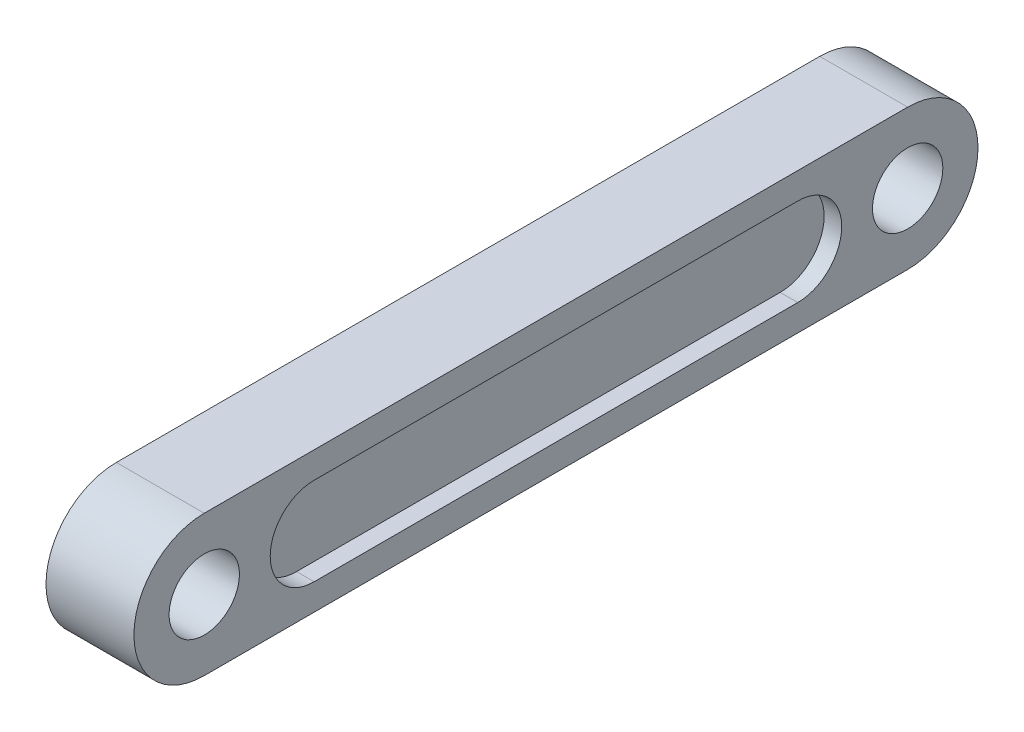
from build123d import *

# Parameters (mm, degrees)
SKETCH_1_R          = 4
EXTRUDE_1_DEPTH     = 5
CUT_EXTRUDE_1_DEPTH = 2


with BuildPart() as part:
    # 草图1 → 凸台-拉伸1 (new body, symmetric)
    with BuildSketch(Plane(origin=(0, 0, 0), x_dir=(0, 0, -1), z_dir=(1, 0, 0))):
        with BuildLine():
            Line((-40, 8), (40, 8))
            ThreePointArc((40, 8), (48, 0), (40, -8))
            Line((40, -8), (-40, -8))
            ThreePointArc((-40, -8), (-48, 0), (-40, 8))
        make_face()
        with Locations((40, 0)):
            Circle(SKETCH_1_R, mode=Mode.SUBTRACT)
        with Locations((-40, 0)):
            Circle(SKETCH_1_R, mode=Mode.SUBTRACT)
    extrude(amount=EXTRUDE_1_DEPTH, both=True)

    # 草图2 → 切除-拉伸1 (cut)
    with BuildSketch(Plane.ZY.offset(5)):
        with BuildLine():
            Line((-27.5, 5), (27.5, 5))
            ThreePointArc((27.5, 5), (32.5, 0), (27.5, -5))
            Line((27.5, -5), (-27.5, -5))
            ThreePointArc((-27.5, -5), (-32.5, 0), (-27.5, 5))
        make_face()
    cut_extrude_1 = extrude(amount=-CUT_EXTRUDE_1_DEPTH, mode=Mode.SUBTRACT)

    # 镜向1: 切除-拉伸1 across plane
    add(cut_extrude_1.mirror(Plane(origin=(0, 0, 0), x_dir=(0, 0, 1), z_dir=(1, 0, 0))), mode=Mode.SUBTRACT)


solid = part.part
